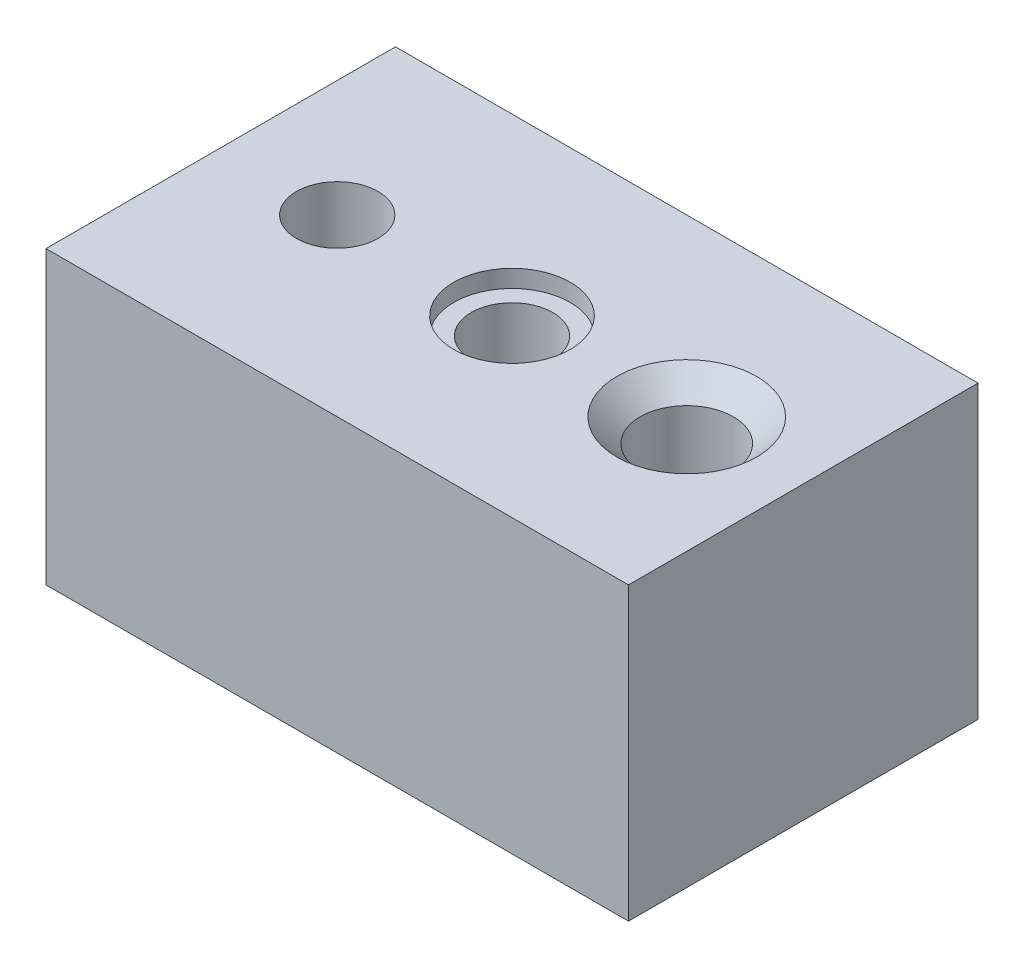
from build123d import *

# Parameters (mm, degrees)
SKETCH1_W                                       = 100
SKETCH1_H                                       = 60
BOSS_EXTRUDE1_DEPTH                             = 50
CBORE_FOR_M5_HEX_HEAD_BOLT1_D                   = 14
CBORE_FOR_M5_HEX_HEAD_BOLT1_DEPTH               = 16
CBORE_FOR_M5_HEX_HEAD_BOLT1_CBORE_D             = 20
CBORE_FOR_M5_HEX_HEAD_BOLT1_CBORE_DEPTH         = 3
CBORE_FOR_M5_HEX_HEAD_BOLT1_TIP                 = 4.206024333
CSK_FOR_M5_FLAT_HEAD_MACHINE_SCREW1_D           = 16
CSK_FOR_M5_FLAT_HEAD_MACHINE_SCREW1_DEPTH       = 16
CSK_FOR_M5_FLAT_HEAD_MACHINE_SCREW1_CSINK_D     = 24
CSK_FOR_M5_FLAT_HEAD_MACHINE_SCREW1_CSINK_ANGLE = 90
CSK_FOR_M5_FLAT_HEAD_MACHINE_SCREW1_TIP         = 4.806884952
M16X2_0_TAPPED_HOLE1_D                          = 14


with BuildPart() as part:
    # Sketch1 → Boss-Extrude1 (new body)
    with BuildSketch(Plane(origin=(0, 0, 0), x_dir=(1, 0, 0), z_dir=(0, 1, 0))):
        with Locations((50, 30)):
            Rectangle(SKETCH1_W, SKETCH1_H)
    extrude(amount=-BOSS_EXTRUDE1_DEPTH)

    # CBORE for M5 Hex Head Bolt1
    with Locations(Plane(origin=(0, 0, 0), x_dir=(1, 0, 0), z_dir=(0, 1, 0))):
        with Locations((50, 30)):
            CounterBoreHole(CBORE_FOR_M5_HEX_HEAD_BOLT1_D / 2, CBORE_FOR_M5_HEX_HEAD_BOLT1_CBORE_D / 2, CBORE_FOR_M5_HEX_HEAD_BOLT1_CBORE_DEPTH, depth=CBORE_FOR_M5_HEX_HEAD_BOLT1_DEPTH)
            with Locations((0, 0, -(CBORE_FOR_M5_HEX_HEAD_BOLT1_DEPTH + CBORE_FOR_M5_HEX_HEAD_BOLT1_TIP / 2))):  # 118° drill point
                Cone(0, CBORE_FOR_M5_HEX_HEAD_BOLT1_D / 2, CBORE_FOR_M5_HEX_HEAD_BOLT1_TIP, mode=Mode.SUBTRACT)

    # CSK for M5 Flat Head Machine Screw1
    with Locations(Plane(origin=(0, 0, 0), x_dir=(1, 0, 0), z_dir=(0, 1, 0))):
        with Locations((80, 30)):
            CounterSinkHole(CSK_FOR_M5_FLAT_HEAD_MACHINE_SCREW1_D / 2, CSK_FOR_M5_FLAT_HEAD_MACHINE_SCREW1_CSINK_D / 2, depth=CSK_FOR_M5_FLAT_HEAD_MACHINE_SCREW1_DEPTH, counter_sink_angle=CSK_FOR_M5_FLAT_HEAD_MACHINE_SCREW1_CSINK_ANGLE)
            with Locations((0, 0, -(CSK_FOR_M5_FLAT_HEAD_MACHINE_SCREW1_DEPTH + CSK_FOR_M5_FLAT_HEAD_MACHINE_SCREW1_TIP / 2))):  # 118° drill point
                Cone(0, CSK_FOR_M5_FLAT_HEAD_MACHINE_SCREW1_D / 2, CSK_FOR_M5_FLAT_HEAD_MACHINE_SCREW1_TIP, mode=Mode.SUBTRACT)

    # M16x2.0 Tapped Hole1 (through all)
    with Locations(Plane(origin=(0, 0, 0), x_dir=(1, 0, 0), z_dir=(0, 1, 0))):
        with Locations((20, 30)):
            Hole(M16X2_0_TAPPED_HOLE1_D / 2)


solid = part.part
